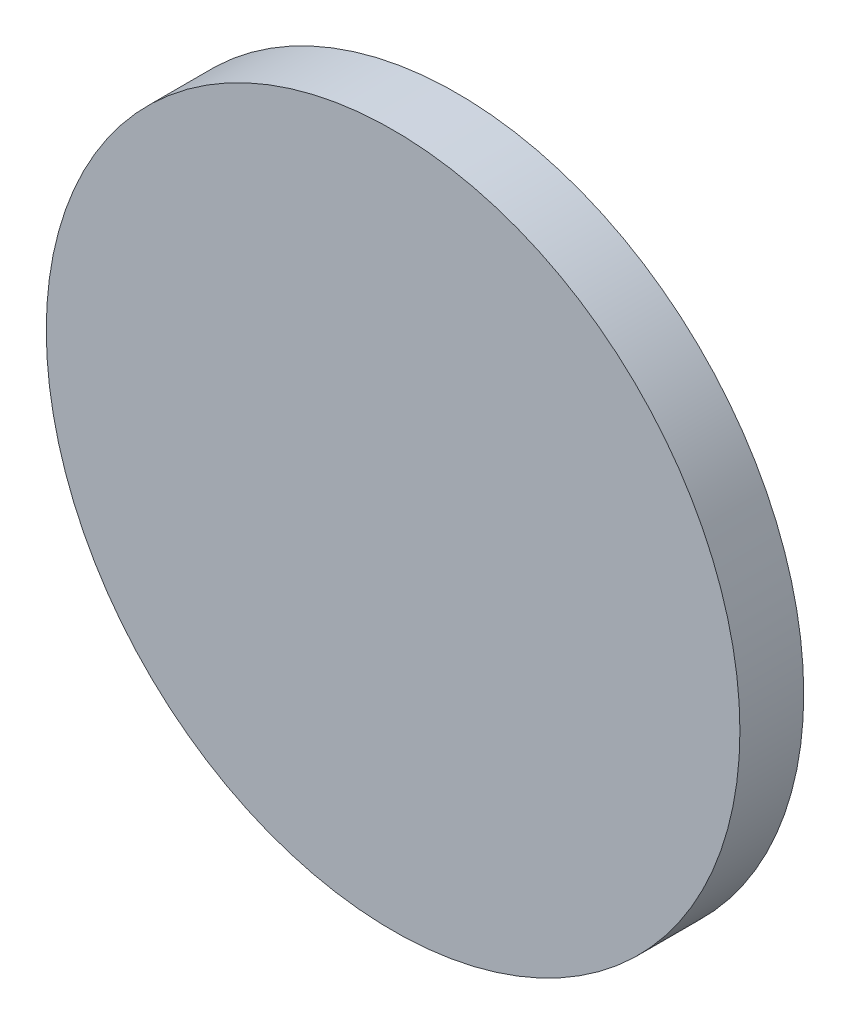
from build123d import *

# Parameters (mm, degrees)
SKETCH_1_R      = 12.5
EXTRUDE_1_DEPTH = 2.3


with BuildPart() as part:
    # 草图1 → 凸台-拉伸1 (new body)
    with BuildSketch(Plane.XY):
        with Locations((101.247935776, 61.563241835)):
            Circle(SKETCH_1_R)
    extrude(amount=EXTRUDE_1_DEPTH)


solid = part.part
